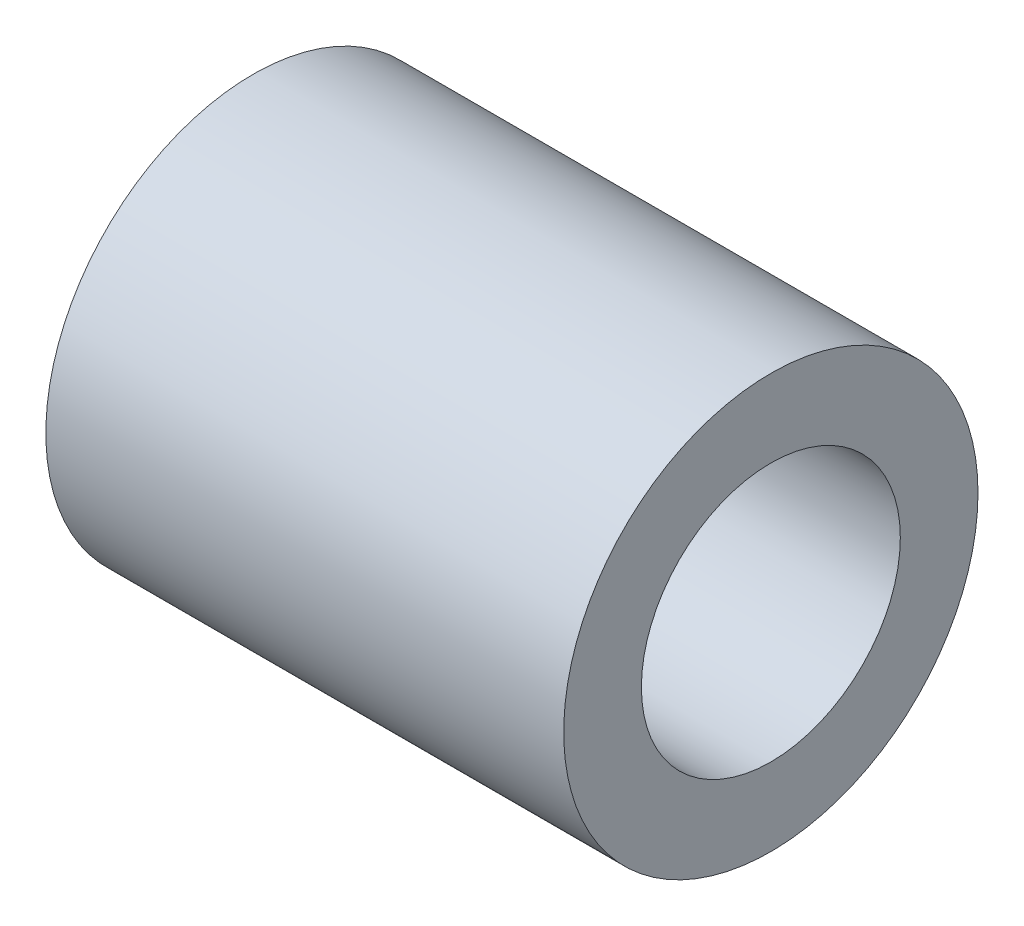
from build123d import *

# Parameters (mm, degrees)
SKETCH_1_R      = 4
SKETCH_1_R_2    = 2.5
EXTRUDE_1_DEPTH = 10


with BuildPart() as part:
    # 草图1 → 凸台-拉伸1 (new body)
    with BuildSketch(Plane(origin=(0, 0, 0), x_dir=(0, 0, -1), z_dir=(1, 0, 0))):
        Circle(SKETCH_1_R)
        Circle(SKETCH_1_R_2, mode=Mode.SUBTRACT)
    extrude(amount=EXTRUDE_1_DEPTH)


solid = part.part
